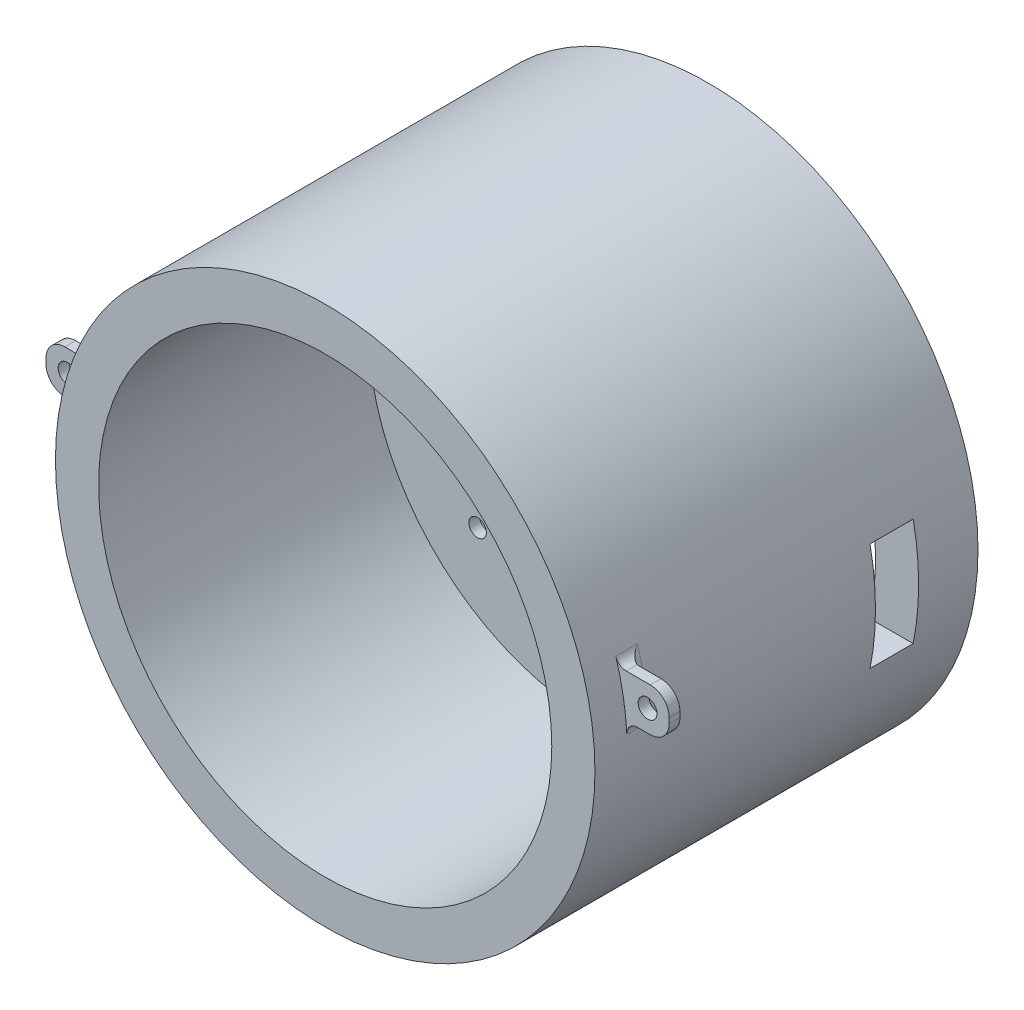
from build123d import *

# Parameters (mm, degrees)
ESQUISSE1_R                  = 50
BOSS_EXTRU_1_DEPTH           = 71
COQUE1_T                     = -8
ESQUISSE2_R                  = 42
ESQUISSE2_R_2                = 1.625
ENL_V_MAT_EXTRU_4_DEPTH      = 71
ESQUISSE2_5_R                = 42
ESQUISSE2_5_R_2              = 1.625
BOSS_EXTRU_4_DEPTH           = 52
ESQUISSE2_6_R                = 42
ESQUISSE2_6_R_2              = 1.625
ENL_V_MAT_EXTRU_5_DEPTH      = 50
ENL_V_MAT_EXTRU_6_REACH      = 102.205
ESQUISSE2_7_R                = 1.625
ENL_V_MAT_EXTRU_7_REACH      = 134.442
ENL_V_MAT_EXTRU_7_END_RADIUS = 42
ESQUISSE9_W                  = 8
ESQUISSE9_H                  = 20
ESQUISSE14_R                 = 1.75
BOSS_EXTRU_6_DEPTH           = 2
CONG_1_R                     = 2
CONG_2_R                     = 3.5


with BuildPart() as part:
    # Esquisse1 → Boss.-Extru.1 (new body)
    with BuildSketch(Plane.XY):
        Circle(ESQUISSE1_R)
    extrude(amount=BOSS_EXTRU_1_DEPTH)

    # Coque1
    coque1_openings = [part.faces().sort_by_distance(p)[0] for p in [
        (0, 0, 71),
    ]]
    offset(amount=COQUE1_T, openings=coque1_openings, kind=Kind.INTERSECTION)

    # Esquisse2 → Enl_v. mat.-Extru.4 (cut)
    with BuildSketch(Plane.XY.offset(71)):
        Circle(ESQUISSE2_R)
        with Locations((-21.75, -21.75)):
            Circle(ESQUISSE2_R_2, mode=Mode.SUBTRACT)
        with Locations((21.75, -21.75)):
            Circle(ESQUISSE2_R_2, mode=Mode.SUBTRACT)
        with Locations((21.75, 21.75)):
            Circle(ESQUISSE2_R_2, mode=Mode.SUBTRACT)
        with Locations((-21.75, 21.75)):
            Circle(ESQUISSE2_R_2, mode=Mode.SUBTRACT)
        with Locations((-21.75, 21.75)):
            Circle(ESQUISSE2_R_2)
        with Locations((-21.75, -21.75)):
            Circle(ESQUISSE2_R_2)
        with Locations((21.75, -21.75)):
            Circle(ESQUISSE2_R_2)
        with Locations((21.75, 21.75)):
            Circle(ESQUISSE2_R_2)
    extrude(amount=-ENL_V_MAT_EXTRU_4_DEPTH, mode=Mode.SUBTRACT)

    # Esquisse2_5 → Boss.-Extru.4 (add)
    with BuildSketch(Plane.XY.offset(71)):
        Circle(ESQUISSE2_5_R)
        with Locations((-21.75, -21.75)):
            Circle(ESQUISSE2_5_R_2, mode=Mode.SUBTRACT)
        with Locations((21.75, -21.75)):
            Circle(ESQUISSE2_5_R_2, mode=Mode.SUBTRACT)
        with Locations((21.75, 21.75)):
            Circle(ESQUISSE2_5_R_2, mode=Mode.SUBTRACT)
        with Locations((-21.75, 21.75)):
            Circle(ESQUISSE2_5_R_2, mode=Mode.SUBTRACT)
        with Locations((-21.75, 21.75)):
            Circle(ESQUISSE2_5_R_2)
        with Locations((21.75, 21.75)):
            Circle(ESQUISSE2_5_R_2)
        with Locations((21.75, -21.75)):
            Circle(ESQUISSE2_5_R_2)
        with Locations((-21.75, -21.75)):
            Circle(ESQUISSE2_5_R_2)
    extrude(amount=-BOSS_EXTRU_4_DEPTH)

    # Esquisse2_6 → Enl_v. mat.-Extru.5 (cut)
    with BuildSketch(Plane.XY.offset(71)):
        Circle(ESQUISSE2_6_R)
        with Locations((-21.75, 21.75)):
            Circle(ESQUISSE2_6_R_2, mode=Mode.SUBTRACT)
        with Locations((21.75, 21.75)):
            Circle(ESQUISSE2_6_R_2, mode=Mode.SUBTRACT)
        with Locations((21.75, -21.75)):
            Circle(ESQUISSE2_6_R_2, mode=Mode.SUBTRACT)
        with Locations((-21.75, -21.75)):
            Circle(ESQUISSE2_6_R_2, mode=Mode.SUBTRACT)
    extrude(amount=-ENL_V_MAT_EXTRU_5_DEPTH, mode=Mode.SUBTRACT)

    # Esquisse2_7 → Enl_v. mat.-Extru.6 (cut, up to next)
    with BuildSketch(Plane.XY.offset(71), mode=Mode.PRIVATE) as enl_v_mat_extru_6_sk1:
        with Locations((-21.75, 21.75)):
            Circle(ESQUISSE2_7_R)
    enl_v_mat_extru_6_tool1 = extrude(enl_v_mat_extru_6_sk1.sketch, amount=-ENL_V_MAT_EXTRU_6_REACH, mode=Mode.PRIVATE) & part.part
    # Esquisse2_7 → Enl_v. mat.-Extru.6 (cut, up to next)
    with BuildSketch(Plane.XY.offset(71), mode=Mode.PRIVATE) as enl_v_mat_extru_6_sk2:
        with Locations((21.75, 21.75)):
            Circle(ESQUISSE2_7_R)
    enl_v_mat_extru_6_tool2 = extrude(enl_v_mat_extru_6_sk2.sketch, amount=-ENL_V_MAT_EXTRU_6_REACH, mode=Mode.PRIVATE) & part.part
    # Esquisse2_7 → Enl_v. mat.-Extru.6 (cut, up to next)
    with BuildSketch(Plane.XY.offset(71), mode=Mode.PRIVATE) as enl_v_mat_extru_6_sk3:
        with Locations((21.75, -21.75)):
            Circle(ESQUISSE2_7_R)
    enl_v_mat_extru_6_tool3 = extrude(enl_v_mat_extru_6_sk3.sketch, amount=-ENL_V_MAT_EXTRU_6_REACH, mode=Mode.PRIVATE) & part.part
    # Esquisse2_7 → Enl_v. mat.-Extru.6 (cut, up to next)
    with BuildSketch(Plane.XY.offset(71), mode=Mode.PRIVATE) as enl_v_mat_extru_6_sk4:
        with Locations((-21.75, -21.75)):
            Circle(ESQUISSE2_7_R)
    enl_v_mat_extru_6_tool4 = extrude(enl_v_mat_extru_6_sk4.sketch, amount=-ENL_V_MAT_EXTRU_6_REACH, mode=Mode.PRIVATE) & part.part
    add(enl_v_mat_extru_6_tool1.solids().sort_by_distance((-21.75, 21.75, 71))[0], mode=Mode.SUBTRACT)
    add(enl_v_mat_extru_6_tool2.solids().sort_by_distance((21.75, 21.75, 71))[0], mode=Mode.SUBTRACT)
    add(enl_v_mat_extru_6_tool3.solids().sort_by_distance((21.75, -21.75, 71))[0], mode=Mode.SUBTRACT)
    add(enl_v_mat_extru_6_tool4.solids().sort_by_distance((-21.75, -21.75, 71))[0], mode=Mode.SUBTRACT)

    # Enl_v. mat.-Extru.7: up to this cylinder (the profile starts outside it)
    enl_v_mat_extru_7_end = Plane(origin=(0, 0, 15), z_dir=(0, 0, -1)) * Cylinder(ENL_V_MAT_EXTRU_7_END_RADIUS, 353.884, mode=Mode.PRIVATE)
    # Esquisse9 → Enl_v. mat.-Extru.7 (cut, up to the surface)
    with BuildSketch(Plane(origin=(50, 0, 0), x_dir=(0, 0, -1), z_dir=(1, 0, 0)), mode=Mode.PRIVATE) as enl_v_mat_extru_7_sk1:
        with Locations((-15, 0)):
            Rectangle(ESQUISSE9_W, ESQUISSE9_H)
    enl_v_mat_extru_7_tool1 = extrude(enl_v_mat_extru_7_sk1.sketch, amount=-ENL_V_MAT_EXTRU_7_REACH, mode=Mode.PRIVATE) - enl_v_mat_extru_7_end
    add(enl_v_mat_extru_7_tool1.solids().sort_by_distance((50, 0, 15))[0], mode=Mode.SUBTRACT)

    # Esquisse14 → Boss.-Extru.6 (add)
    with BuildSketch(Plane.XY.offset(65)):
        with BuildLine():
            Line((49.749371855, 5), (57.749371855, 5))
            Line((57.749371855, 5), (57.749371855, 13))
            Line((57.749371855, 13), (48.280430818, 13))
            ThreePointArc((48.280430818, 13), (49.177846161, 9.029919542), (49.749371855, 5))
        make_face()
        with Locations((53.749371855, 9)):
            Circle(ESQUISSE14_R, mode=Mode.SUBTRACT)
    boss_extru_6 = extrude(amount=-BOSS_EXTRU_6_DEPTH)

    # Sym_trie1: Boss.-Extru.6 across plane
    add(boss_extru_6.mirror(Plane(origin=(0, 0, 0), x_dir=(0, 0, 1), z_dir=(1, 0, 0))))

    # Cong_1
    cong_1_edges = [part.edges().sort_by_distance(p)[0] for p in [
        (49.749371855, 5, 64),
        (48.280430818, 13, 64),
        (49.177846161, 9.029919542, 63),
        (-49.177846161, 9.029919542, 63),
        (-48.280430818, 13, 64),
        (-49.749371855, 5, 64),
    ]]
    fillet(cong_1_edges, radius=CONG_1_R)

    # Cong_2
    cong_2_edges = [part.edges().sort_by_distance(p)[0] for p in [
        (57.749371855, 13, 64),
        (57.749371855, 5, 64),
        (-57.749371855, 5, 64),
        (-57.749371855, 13, 64),
    ]]
    fillet(cong_2_edges, radius=CONG_2_R)


solid = part.part
